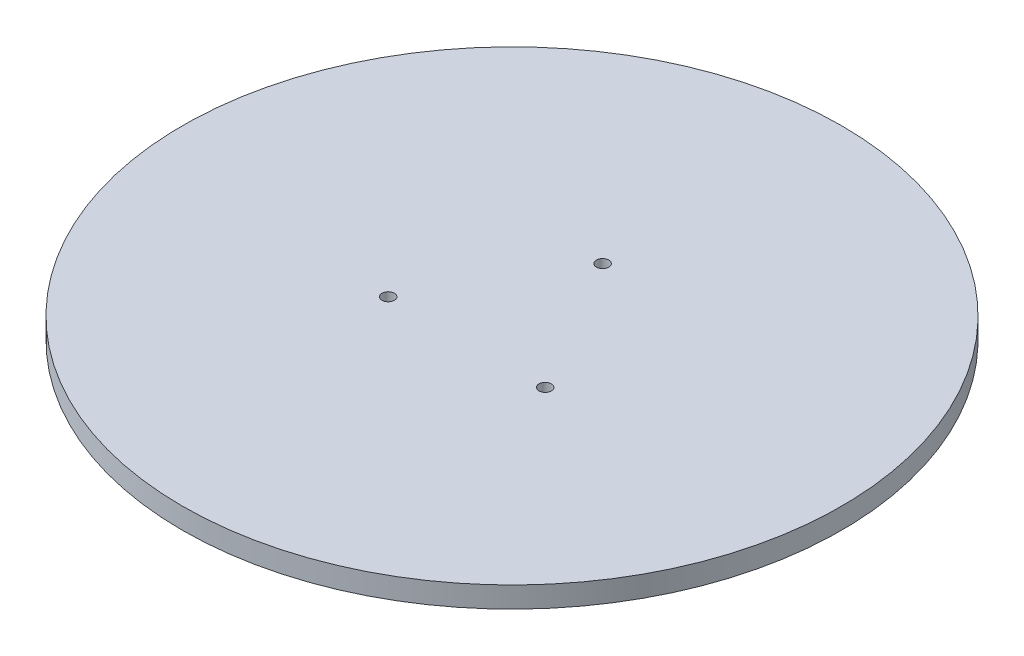
from build123d import *

# Parameters (mm, degrees)
SKETCH1_R           = 40
BOSS_EXTRUDE1_DEPTH = 2.54
SKETCH2_R           = 0.75
CUT_EXTRUDE1_DEPTH  = 10
SKETCH3_R           = 30.7
SKETCH3_R_2         = 26.7
BOSS_EXTRUDE2_DEPTH = 0.254


with BuildPart() as part:
    # Sketch1 → Boss-Extrude1 (new body)
    with BuildSketch(Plane(origin=(0, 0, 0), x_dir=(1, 0, 0), z_dir=(0, 1, 0))):
        Circle(SKETCH1_R)
    extrude(amount=BOSS_EXTRUDE1_DEPTH)

    # Sketch2 → Cut-Extrude1 (cut)
    with BuildSketch(Plane(origin=(0, 2.54, 0), x_dir=(1, 0, 0), z_dir=(0, 1, 0))):
        with Locations((0, 11)):
            Circle(SKETCH2_R)
        with Locations((9.526279442, -5.5)):
            Circle(SKETCH2_R)
        with Locations((-9.526279442, -5.5)):
            Circle(SKETCH2_R)
    extrude(amount=-CUT_EXTRUDE1_DEPTH, mode=Mode.SUBTRACT)

    # Sketch3 → Boss-Extrude2 (add)
    with BuildSketch(Plane.XZ):
        Circle(SKETCH3_R)
        Circle(SKETCH3_R_2, mode=Mode.SUBTRACT)
    extrude(amount=BOSS_EXTRUDE2_DEPTH)


solid = part.part
